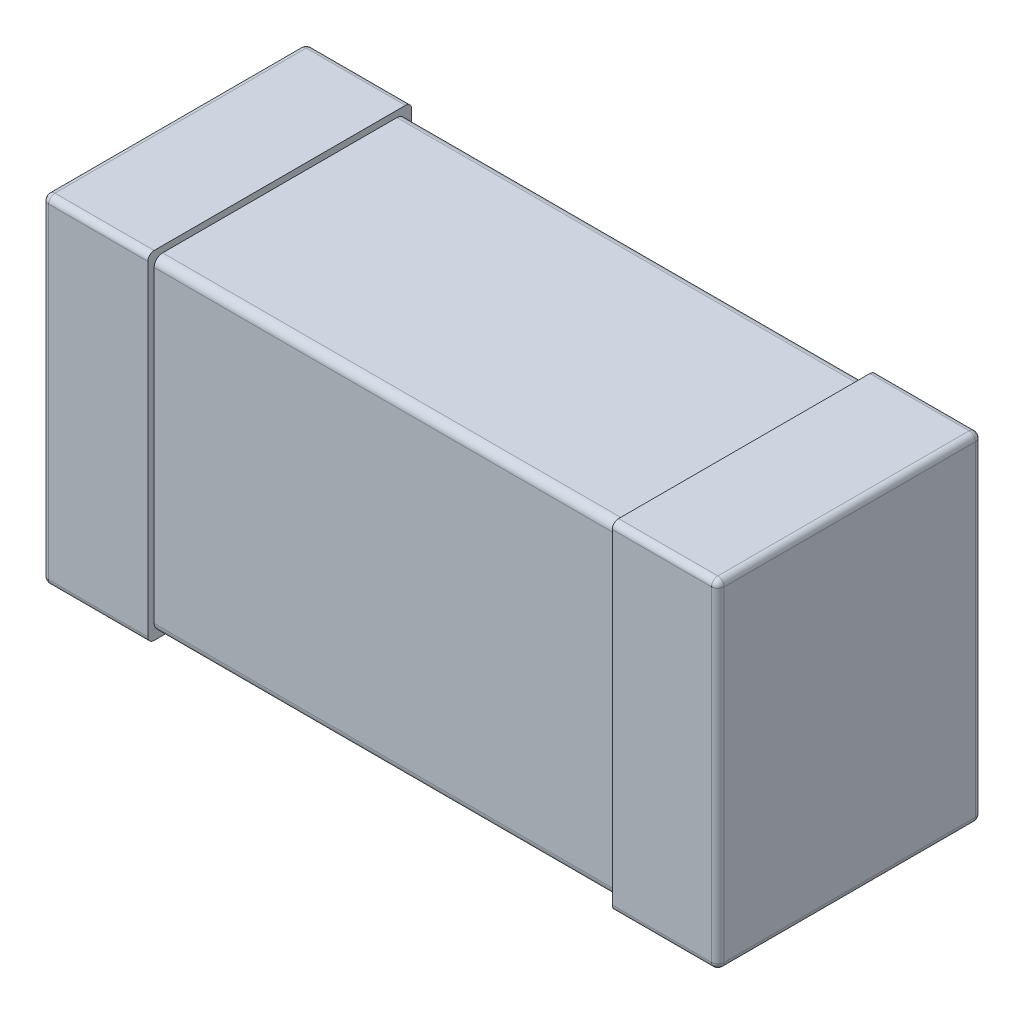
from build123d import *

# Parameters (mm, degrees)
EXTRUDE_START   = 0.03
SKETCH_2_W      = 2.2
SKETCH_2_H      = 1.54
EXTRUDE_2_DEPTH = 1.19
SKETCH_3_W      = 0.5
SKETCH_3_H      = 1.6
EXTRUDE_3_DEPTH = 1.25
FILLET_1_R      = 0.04
FILLET_2_R      = 0.03


with BuildPart() as part:
    # Эскиз2 → Вытянуть2 (new body)
    with BuildSketch(Plane.XY.offset(EXTRUDE_START)):
        Rectangle(SKETCH_2_W, SKETCH_2_H)
    extrude(amount=EXTRUDE_2_DEPTH)

    # Эскиз3 → Вытянуть3 (add)
    with BuildSketch(Plane.XY):
        with Locations((1.35, 0)):
            Rectangle(SKETCH_3_W, SKETCH_3_H)
        with Locations((-1.35, 0)):
            Rectangle(SKETCH_3_W, SKETCH_3_H)
    extrude(amount=EXTRUDE_3_DEPTH)

    # Скругление1
    fillet_1_edges = [part.edges().sort_by_distance(p)[0] for p in [
        (0, -0.77, 1.22),
        (0, -0.77, 0.03),
        (0, 0.77, 0.03),
        (0, 0.77, 1.22),
    ]]
    fillet(fillet_1_edges, radius=FILLET_1_R)

    # Скругление2
    fillet_2_edges = [part.edges().sort_by_distance(p)[0] for p in [
        (1.35, -0.8, 0),
        (1.6, 0, 0),
        (1.6, -0.8, 0.625),
        (1.35, 0.8, 0),
        (1.6, 0.8, 0.625),
        (1.35, -0.8, 1.25),
        (1.6, 0, 1.25),
        (1.35, 0.8, 1.25),
        (-1.35, 0.8, 0),
        (-1.6, 0, 0),
        (-1.6, 0.8, 0.625),
        (-1.35, -0.8, 0),
        (-1.6, -0.8, 0.625),
        (-1.35, 0.8, 1.25),
        (-1.6, 0, 1.25),
        (-1.35, -0.8, 1.25),
    ]]
    fillet(fillet_2_edges, radius=FILLET_2_R)


solid = part.part
